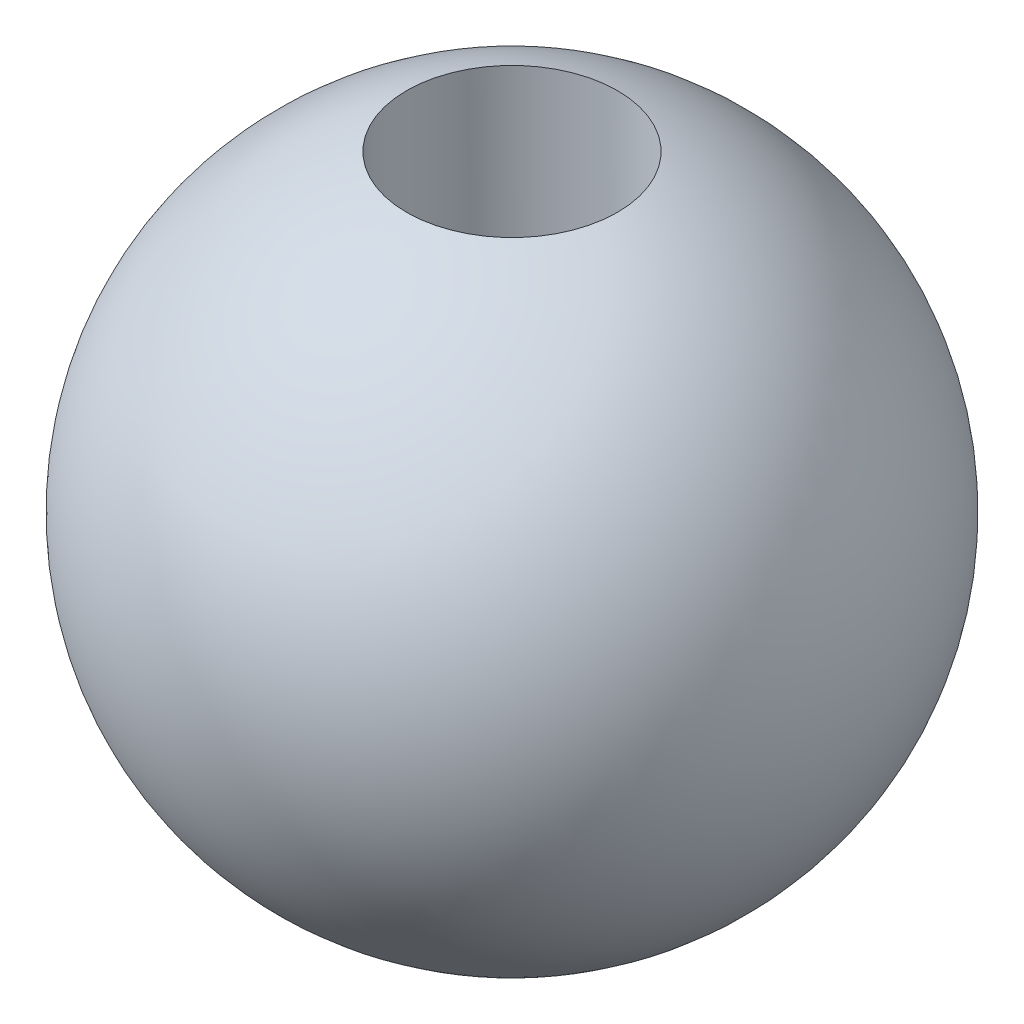
from build123d import *

# Parameters (mm, degrees)
SKIZZE3_R                       = 4
SCHNITT_LINEAR_AUSTRAGEN1_DEPTH = 20


with BuildPart() as part:
    # Skizze1 → Rotation1 (revolve)
    with BuildSketch(Plane.XY):
        with BuildLine():
            Line((0, 12.5), (0, -12.5))
            ThreePointArc((0, -12.5), (-12.5, 0), (0, 12.5))
        make_face()
    revolve(axis=Axis((0, 27.42628623, 0), (0, -1, 0)))

    # Skizze3 → Schnitt-Linear austragen1 (cut, symmetric)
    with BuildSketch(Plane(origin=(0, 0, 0), x_dir=(1, 0, 0), z_dir=(0, 1, 0))):
        Circle(SKIZZE3_R)
    extrude(amount=SCHNITT_LINEAR_AUSTRAGEN1_DEPTH, both=True, mode=Mode.SUBTRACT)

    # Skizze5 → Rotation2 (revolve)
    with BuildSketch(Plane(origin=(0, 0, 0), x_dir=(0, 0, -1), z_dir=(1, 0, 0))):
        Polygon((-2.15, 0), (-2.15, 2), (-5, 3.712452764), (-5, 0), align=None)
    rotation2 = revolve(axis=Axis((0, 0, 0), (0, 1, 0)))

    # Spiegeln1: Rotation2 across plane
    add(rotation2.mirror(Plane.ZX))


solid = part.part
